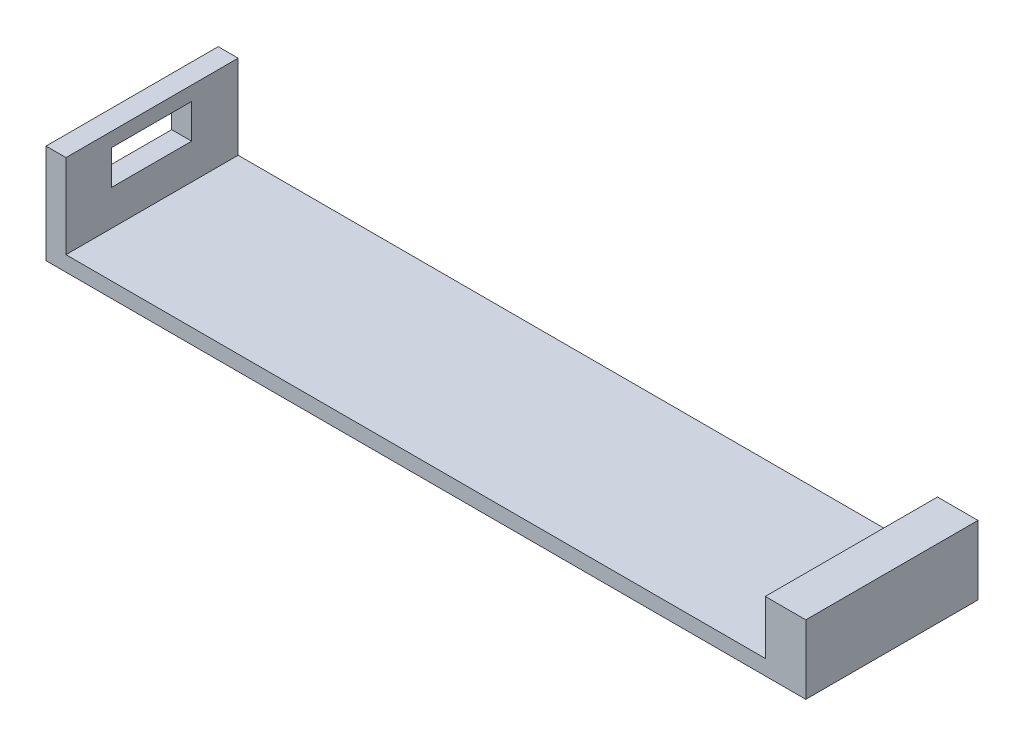
from build123d import *

# Parameters (mm, degrees)
SKETCH1_W           = 75
SKETCH1_H           = 17
BOSS_EXTRUDE1_DEPTH = 1.5
SKETCH2_W           = 4
SKETCH2_H           = 17
SKETCH2_W_2         = 1.969333236
BOSS_EXTRUDE2_DEPTH = 5.3
SKETCH3_W           = 14.056018955
SKETCH3_H           = 1.3
CUT_EXTRUDE1_DEPTH  = 2.1
SKETCH4_W           = 1.969333236
SKETCH4_H           = 17
BOSS_EXTRUDE3_DEPTH = 3
SKETCH5_W           = 7.906104095
SKETCH5_H           = 3.4
CUT_EXTRUDE3_DEPTH  = 33


with BuildPart() as part:
    # Sketch1 → Boss-Extrude1 (new body)
    with BuildSketch(Plane(origin=(0, 0, 0), x_dir=(1, 0, 0), z_dir=(0, 1, 0))):
        with Locations((-3.550742823, -7.98686986)):
            Rectangle(SKETCH1_W, SKETCH1_H)
    extrude(amount=BOSS_EXTRUDE1_DEPTH)

    # Sketch2 → Boss-Extrude2 (add)
    with BuildSketch(Plane(origin=(0, 1.5, 0), x_dir=(1, 0, 0), z_dir=(0, 1, 0))):
        with Locations((31.949257177, -7.98686986)):
            Rectangle(SKETCH2_W, SKETCH2_H)
        with Locations((-40.066076205, -7.98686986)):
            Rectangle(SKETCH2_W_2, SKETCH2_H)
    extrude(amount=BOSS_EXTRUDE2_DEPTH)

    # Sketch3 → Cut-Extrude1 (cut)
    with BuildSketch(Plane.ZY.offset(-29.949257177)):
        with Locations((8.014879338, 4.15)):
            Rectangle(SKETCH3_W, SKETCH3_H)
    extrude(amount=-CUT_EXTRUDE1_DEPTH, mode=Mode.SUBTRACT)

    # Sketch4 → Boss-Extrude3 (add)
    with BuildSketch(Plane(origin=(0, 6.8, 0), x_dir=(1, 0, 0), z_dir=(0, 1, 0))):
        with Locations((-40.066076205, -7.98686986)):
            Rectangle(SKETCH4_W, SKETCH4_H)
    extrude(amount=BOSS_EXTRUDE3_DEPTH)

    # Sketch5 → Cut-Extrude3 (cut)
    with BuildSketch(Plane(origin=(-39.081409587, 0, 0), x_dir=(0, 0, -1), z_dir=(1, 0, 0))):
        with Locations((-8.033817813, 6.7)):
            Rectangle(SKETCH5_W, SKETCH5_H)
    extrude(amount=-CUT_EXTRUDE3_DEPTH, mode=Mode.SUBTRACT)


solid = part.part
